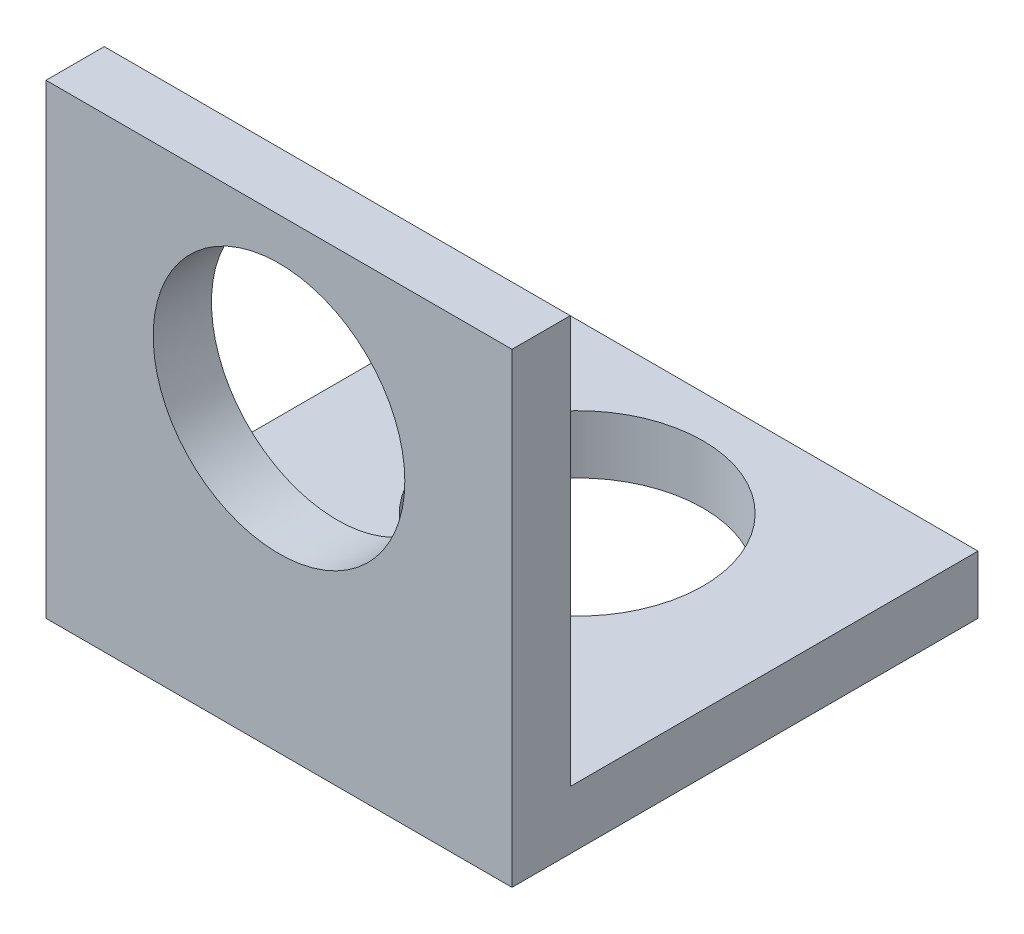
from build123d import *

# Parameters (mm, degrees)
BOSS_EXTRUDE1_DEPTH = 12.7
SKETCH2_R           = 3.429
CUT_EXTRUDE1_DEPTH  = 13.7
SKETCH3_R           = 3.429
CUT_EXTRUDE2_DEPTH  = 13.7


with BuildPart() as part:
    # Sketch1 → Boss-Extrude1 (new body)
    with BuildSketch(Plane(origin=(0, 0, 0), x_dir=(0, 0, -1), z_dir=(1, 0, 0))):
        Polygon((0, 0), (0, 12.7), (1.5875, 12.7), (1.5875, 1.5875), (12.7, 1.5875), (12.7, 0), align=None)
    extrude(amount=BOSS_EXTRUDE1_DEPTH)

    # Sketch2 → Cut-Extrude1 (cut, through all)
    with BuildSketch(Plane.XY):
        with Locations((6.35, 8.128)):
            Circle(SKETCH2_R)
    extrude(amount=-CUT_EXTRUDE1_DEPTH, mode=Mode.SUBTRACT)

    # Sketch3 → Cut-Extrude2 (cut, through all)
    with BuildSketch(Plane.XZ):
        with Locations((6.35, -8.128)):
            Circle(SKETCH3_R)
    extrude(amount=-CUT_EXTRUDE2_DEPTH, mode=Mode.SUBTRACT)


solid = part.part
